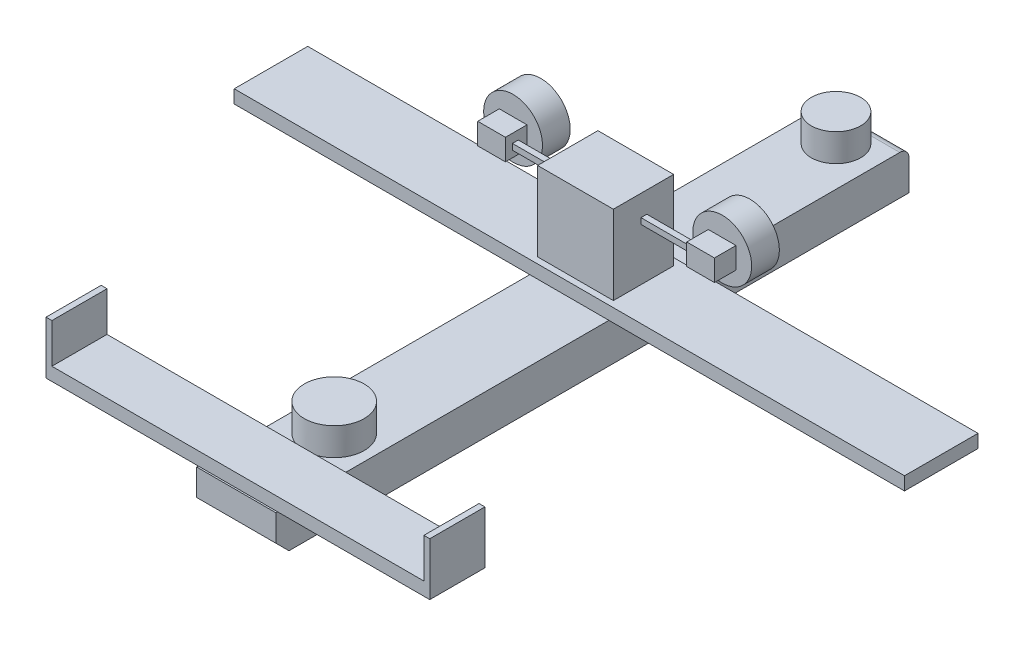
from build123d import *

# Parameters (mm, degrees)
SKETCH1_W           = 152.4
SKETCH1_H           = 76.2
BOSS_EXTRUDE1_DEPTH = 1219.2
FILLET1_R           = 17.78
CHAMFER1_SIZE       = 25.4
SKETCH2_W           = 1290.477589614
SKETCH2_H           = 141.513172698
SKETCH2_W_2         = 738.880843562
SKETCH2_H_2         = 106.185211378
BOSS_EXTRUDE2_DEPTH = 25.4
SKETCH3_W           = 145.88030373
SKETCH3_H           = 116.073932347
BOSS_EXTRUDE3_DEPTH = 152.4
SKETCH4_W           = 11.32867816
SKETCH4_H           = 11.32867816
BOSS_EXTRUDE4_DEPTH = 101.6
SKETCH5_W           = 41.535496856
SKETCH5_H           = 41.006382246
BOSS_EXTRUDE5_DEPTH = 53.34
SKETCH6_R           = 56.660477504
BOSS_EXTRUDE6_DEPTH = 53.34
SKETCH7_R           = 47.532369055
SKETCH7_R_2         = 57.711896929
BOSS_EXTRUDE7_DEPTH = 53.34
SKETCH8_W           = 11.310933435
SKETCH8_H           = 106.185211378
BOSS_EXTRUDE8_DEPTH = 76.2


with BuildPart() as part:
    # Sketch1 → Boss-Extrude1 (new body)
    with BuildSketch(Plane.XY):
        Rectangle(SKETCH1_W, SKETCH1_H)
    extrude(amount=BOSS_EXTRUDE1_DEPTH)

    # Fillet1
    fillet1_edges = [part.edges().sort_by_distance(p)[0] for p in [
        (0, 38.1, 0),
    ]]
    fillet(fillet1_edges, radius=FILLET1_R)

    # Chamfer1
    chamfer1_edges = [part.edges().sort_by_distance(p)[0] for p in [
        (0, -38.1, 1219.2),
    ]]
    chamfer(chamfer1_edges, length=CHAMFER1_SIZE)

    # Sketch2 → Boss-Extrude2 (add)
    with BuildSketch(Plane(origin=(0, 38.1, 0), x_dir=(1, 0, 0), z_dir=(0, 1, 0))):
        with Locations((0, -507.012478725)):
            Rectangle(SKETCH2_W, SKETCH2_H)
        with Locations((0, -1162.865725204)):
            Rectangle(SKETCH2_W_2, SKETCH2_H_2)
    extrude(amount=BOSS_EXTRUDE2_DEPTH)

    # Sketch3 → Boss-Extrude3 (add)
    with BuildSketch(Plane(origin=(0, 63.5, 0), x_dir=(1, 0, 0), z_dir=(0, 1, 0))):
        with Locations((0, -507.950753796)):
            Rectangle(SKETCH3_W, SKETCH3_H)
    extrude(amount=BOSS_EXTRUDE3_DEPTH)

    # Sketch4 → Boss-Extrude4 (add)
    with BuildSketch(Plane.ZY.offset(72.940151865)):
        with Locations((507.221293342, 169.657361137)):
            Rectangle(SKETCH4_W, SKETCH4_H)
    boss_extrude4 = extrude(amount=BOSS_EXTRUDE4_DEPTH)

    # Sketch5 → Boss-Extrude5 (add)
    with BuildSketch(Plane.ZY.offset(174.540151865)):
        with Locations((505.573109598, 171.765287406)):
            Rectangle(SKETCH5_W, SKETCH5_H)
    boss_extrude5 = extrude(amount=BOSS_EXTRUDE5_DEPTH)

    # Sketch6 → Boss-Extrude6 (add)
    with BuildSketch(Plane(origin=(0, 0, 484.80536117), x_dir=(-1, 0, 0), z_dir=(0, 0, -1))):
        with Locations((201.337814598, 173.008334857)):
            Circle(SKETCH6_R)
    boss_extrude6 = extrude(amount=BOSS_EXTRUDE6_DEPTH)

    # Mirror1: Boss-Extrude4, Boss-Extrude5, Boss-Extrude6 across plane
    add(boss_extrude4.mirror(Plane(origin=(0, 0, 0), x_dir=(0, 0, 1), z_dir=(1, 0, 0))))
    add(boss_extrude5.mirror(Plane(origin=(0, 0, 0), x_dir=(0, 0, 1), z_dir=(1, 0, 0))))
    add(boss_extrude6.mirror(Plane(origin=(0, 0, 0), x_dir=(0, 0, 1), z_dir=(1, 0, 0))))

    # Sketch7 → Boss-Extrude7 (add)
    with BuildSketch(Plane(origin=(0, 38.1, 0), x_dir=(1, 0, 0), z_dir=(0, 1, 0))):
        with Locations((0, -64.420131153)):
            Circle(SKETCH7_R)
        with Locations((0, -1030.4765592)):
            Circle(SKETCH7_R_2)
    extrude(amount=BOSS_EXTRUDE7_DEPTH)

    # Sketch8 → Boss-Extrude8 (add)
    with BuildSketch(Plane(origin=(0, 63.5, 0), x_dir=(1, 0, 0), z_dir=(0, 1, 0))):
        with Locations((363.784955063, -1162.865725204)):
            Rectangle(SKETCH8_W, SKETCH8_H)
    boss_extrude8 = extrude(amount=BOSS_EXTRUDE8_DEPTH)

    # Mirror2: Boss-Extrude8 across plane
    add(boss_extrude8.mirror(Plane(origin=(0, 0, 0), x_dir=(0, 0, 1), z_dir=(1, 0, 0))))


solid = part.part
